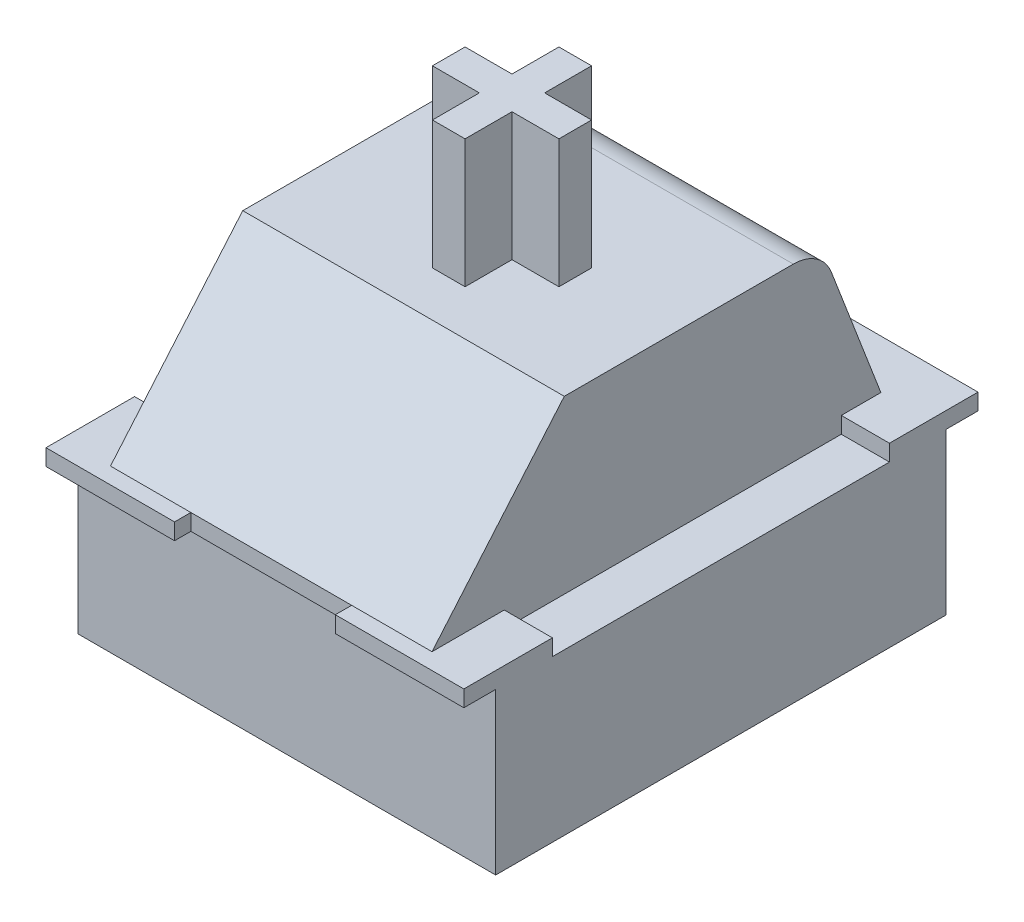
from build123d import *

# Parameters (mm, degrees)
SALIENTE_EXTRUIR1_DEPTH      = 6.5024
SALIENTE_EXTRUIR1_DEPTH_BACK = 6.5024
SALIENTE_EXTRUIR2_DEPTH      = 5.0038
SALIENTE_EXTRUIR2_DEPTH_BACK = 5.0038
CROQUIS1_4_W                 = 5.9944
CROQUIS1_4_H                 = 3.9878
SALIENTE_EXTRUIR3_DEPTH      = 3.4671
SALIENTE_EXTRUIR3_DEPTH_BACK = 3.4671
CROQUIS2_W                   = 5.0038
CROQUIS2_H                   = 0.508
CROQUIS2_H_2                 = 1.524
CROQUIS2_W_2                 = 1.4986
CROQUIS2_H_3                 = 10.4902
CORTAR_EXTRUIR1_DEPTH        = 0.508
CROQUIS3_OUTSIDE_W           = 20.026
CROQUIS3_OUTSIDE_H           = 23.024
CORTAR_EXTRUIR2_DEPTH        = 3.9878
CORTAR_EXTRUIR3_DEPTH        = 3.9878


with BuildPart() as part:
    # Croquis1 → Saliente-Extruir1 (new body, two sides)
    with BuildSketch(Plane(origin=(0, 0, 0), x_dir=(0, 0, -1), z_dir=(1, 0, 0))) as saliente_extruir1_sk:
        Polygon((-3.5052, 3.0099), (-7.493, 3.0099), (-8.001, 3.0099), (-8.001, 2.5019), (-7.0104, 2.5019), (-7.0104, -2.5019), (7.0104, -2.5019), (7.0104, 2.5019), (8.001, 2.5019), (8.001, 3.0099), (6.477, 3.0099), align=None)
    extrude(amount=SALIENTE_EXTRUIR1_DEPTH)
    extrude(saliente_extruir1_sk.sketch, amount=-SALIENTE_EXTRUIR1_DEPTH_BACK)

    # Croquis1_3 → Saliente-Extruir2 (add, two sides)
    with BuildSketch(Plane(origin=(0, 0, 0), x_dir=(0, 0, -1), z_dir=(1, 0, 0))) as saliente_extruir2_sk:
        with BuildLine():
            Line((-2.868527833, 7.8359), (-3.376527833, 7.8359))
            Line((-3.376527833, 7.8359), (-7.493, 3.0099))
            Line((-7.493, 3.0099), (-3.5052, 3.0099))
            Line((-3.5052, 3.0099), (6.477, 3.0099))
            Line((6.477, 3.0099), (4.937272491, 7.021027296))
            ThreePointArc((4.937272491, 7.021027296), (4.47096127, 7.61254026), (3.751625349, 7.8359))
            Line((3.751625349, 7.8359), (3.125872167, 7.8359))
            Line((3.125872167, 7.8359), (-2.868527833, 7.8359))
        make_face()
    extrude(amount=SALIENTE_EXTRUIR2_DEPTH)
    extrude(saliente_extruir2_sk.sketch, amount=-SALIENTE_EXTRUIR2_DEPTH_BACK)

    # Croquis1_4 → Saliente-Extruir3 (add, two sides)
    with BuildSketch(Plane(origin=(0, 0, 0), x_dir=(0, 0, -1), z_dir=(1, 0, 0))) as saliente_extruir3_sk:
        with Locations((0.128672167, 9.8298)):
            Rectangle(CROQUIS1_4_W, CROQUIS1_4_H)
    extrude(amount=SALIENTE_EXTRUIR3_DEPTH)
    extrude(saliente_extruir3_sk.sketch, amount=-SALIENTE_EXTRUIR3_DEPTH_BACK)

    # Croquis2 → Cortar-Extruir1 (cut)
    with BuildSketch(Plane(origin=(0, 3.0099, 0), x_dir=(1, 0, 0), z_dir=(0, 1, 0))):
        with Locations((0, -7.747)):
            Rectangle(CROQUIS2_W, CROQUIS2_H)
        with Locations((0, 7.239)):
            Rectangle(CROQUIS2_W, CROQUIS2_H_2)
        with Locations((-5.7531, 0)):
            Rectangle(CROQUIS2_W_2, CROQUIS2_H_3)
        with Locations((5.7531, 0)):
            Rectangle(CROQUIS2_W_2, CROQUIS2_H_3)
    extrude(amount=-CORTAR_EXTRUIR1_DEPTH, mode=Mode.SUBTRACT)

    # Croquis3 outside → Cortar-Extruir2 (cut)
    with BuildSketch(Plane(origin=(0, 11.8237, 0), x_dir=(1, 0, 0), z_dir=(0, 1, 0))):
        Rectangle(CROQUIS3_OUTSIDE_W, CROQUIS3_OUTSIDE_H)
        Polygon((-3.4671, 3.125872167), (-3.4671, -2.868527833), (-1.9685, -2.868527833), (-1.9685, -2.614527833), (-3.2131, -2.614527833), (-3.2131, 2.871872167), (-1.9685, 2.871872167), (-1.9685, 3.125872167), align=None, mode=Mode.SUBTRACT)
        Polygon((0.508, 1.9685), (-0.508, 1.9685), (-0.508, 0.508), (-1.9685, 0.508), (-1.9685, -0.508), (-0.508, -0.508), (-0.508, -1.9685), (0.508, -1.9685), (0.508, -0.508), (1.9685, -0.508), (1.9685, 0.508), (0.508, 0.508), align=None, mode=Mode.SUBTRACT)
        Polygon((3.2131, 2.871872167), (3.2131, -2.614527833), (1.9685, -2.614527833), (1.9685, -2.868527833), (3.4671, -2.868527833), (3.4671, 3.125872167), (1.9685, 3.125872167), (1.9685, 2.871872167), align=None, mode=Mode.SUBTRACT)
    extrude(amount=-CORTAR_EXTRUIR2_DEPTH, mode=Mode.SUBTRACT)

    # Croquis3_2 → Cortar-Extruir3 (cut)
    with BuildSketch(Plane(origin=(0, 11.8237, 0), x_dir=(1, 0, 0), z_dir=(0, 1, 0))):
        Polygon((-3.4671, 3.125872167), (-3.4671, -2.868527833), (-1.9685, -2.868527833), (-1.9685, -2.614527833), (-3.2131, -2.614527833), (-3.2131, 2.871872167), (-1.9685, 2.871872167), (-1.9685, 3.125872167), align=None)
        Polygon((3.2131, 2.871872167), (3.2131, -2.614527833), (1.9685, -2.614527833), (1.9685, -2.868527833), (3.4671, -2.868527833), (3.4671, 3.125872167), (1.9685, 3.125872167), (1.9685, 2.871872167), align=None)
    extrude(amount=-CORTAR_EXTRUIR3_DEPTH, mode=Mode.SUBTRACT)


solid = part.part
